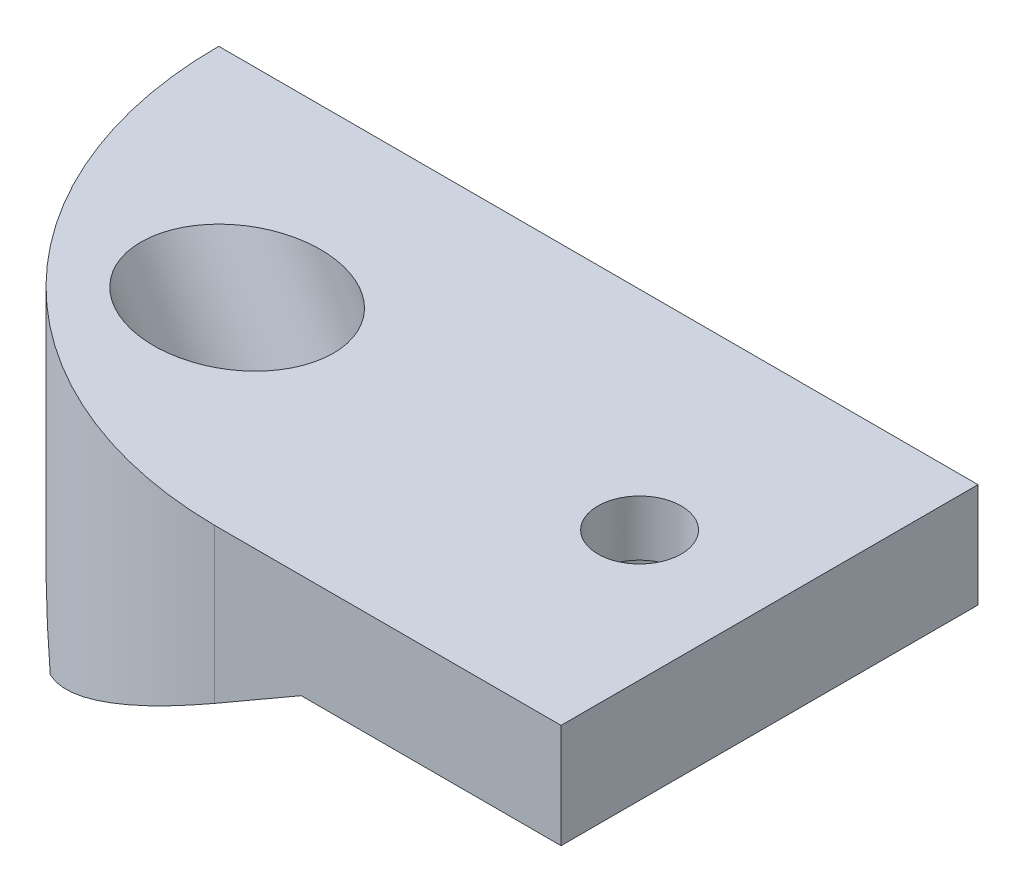
from build123d import *

# Parameters (mm, degrees)
ESBO_O1_W                = 30
ESBO_O1_H                = 30
RESSALTO_EXTRUS_O1_DEPTH = 22.775
CORTE_EXTRUS_O1_DEPTH    = 31
ESBO_O3_OUTSIDE_W        = 48.998
ESBO_O3_OUTSIDE_H        = 41.63
ESBO_O3_OUTSIDE_W_2      = 30
ESBO_O3_OUTSIDE_H_2      = 30
CORTE_EXTRUS_O2_DEPTH    = 20.723728571
RESSALTO_EXTRUS_O2_DEPTH = 30
ESBO_O5_R                = 3.95
CORTE_EXTRUS_O3_DEPTH    = 25.958558799
CORTE_EXTRUS_O5_START    = -8
ESBO_O8_R                = 6
CORTE_EXTRUS_O5_DEPTH    = 25
RESSALTO_EXTRUS_O6_DEPTH = 30
CORTE_EXTRUS_O11_DEPTH   = 26
ESBO_O19_R               = 6.35
CORTE_EXTRUS_O12_DEPTH   = 3.5
ESBO_O20_R               = 3
CORTE_EXTRUS_O13_DEPTH   = 26


with BuildPart() as part:
    # Esboço1 → Ressalto-extrusão1 (new body)
    with BuildSketch(Plane(origin=(0, 0, 0), x_dir=(1, 0, 0), z_dir=(0, 1, 0))):
        Rectangle(ESBO_O1_W, ESBO_O1_H)
    extrude(amount=RESSALTO_EXTRUS_O1_DEPTH)

    # Esboço2 → Corte-extrusão1 (cut, through all)
    with BuildSketch(Plane.XY.offset(15)):
        Polygon((-15, 0), (15, 17.320508076), (15, 0), align=None)
    extrude(amount=-CORTE_EXTRUS_O1_DEPTH, mode=Mode.SUBTRACT)

    # Esboço3 outside → Corte-extrusão2 (cut, through all)
    with BuildSketch(Plane(origin=(-3.75, 6.495190528, 0), x_dir=(0.866025404, 0.5, 0), z_dir=(0.5, -0.866025404, 0))):
        with Locations((5.694, 0)):
            Rectangle(ESBO_O3_OUTSIDE_W, ESBO_O3_OUTSIDE_H)
        with Locations((4.330127019, 0)):
            Rectangle(ESBO_O3_OUTSIDE_W_2, ESBO_O3_OUTSIDE_H_2, mode=Mode.SUBTRACT)
    extrude(amount=-CORTE_EXTRUS_O2_DEPTH, mode=Mode.SUBTRACT)

    # Esboço4 → Ressalto-extrusão2 (add)
    with BuildSketch(Plane.XY.offset(15)):
        Polygon((-25.469660456, 22.775), (-15, 4.641016151), (-15, 22.775), align=None)
    extrude(amount=-RESSALTO_EXTRUS_O2_DEPTH)

    # Esboço5 → Corte-extrusão3 (cut, through all)
    with BuildSketch(Plane(origin=(-3.75, 6.495190528, 0), x_dir=(-0.866025404, -0.5, 0), z_dir=(0.5, -0.866025404, 0))):
        with Locations((-4.330131096, -4.077e-06)):
            Circle(ESBO_O5_R)
    extrude(amount=-CORTE_EXTRUS_O3_DEPTH, mode=Mode.SUBTRACT)

    # Esboço8 → Corte-extrusão5 (cut)
    with BuildSketch(Plane(origin=(-3.75, 6.495190528, 0), x_dir=(0.866025404, 0.5, 0), z_dir=(0.5, -0.866025404, 0)).offset(CORTE_EXTRUS_O5_START)):
        with Locations((4.330131096, 4.077e-06)):
            Circle(ESBO_O8_R)
    extrude(amount=-CORTE_EXTRUS_O5_DEPTH, mode=Mode.SUBTRACT)

    # Esboço16 → Ressalto-extrusão6 (add)
    with BuildSketch(Plane.XY.offset(15)):
        Polygon((9.171355695, 22.775), (30.157076086, 22.775), (30.157076086, 15.275), (11.457076086, 15.275), align=None)
    extrude(amount=-RESSALTO_EXTRUS_O6_DEPTH)

    # Esboço17 → Corte-extrusão11 (cut)
    with BuildSketch(Plane(origin=(0, 22.775, 0), x_dir=(1, 0, 0), z_dir=(0, 1, 0))):
        with BuildLine():
            Line((5.221968449, -14.998459918), (5.221968449, -42.526473986))
            Line((5.221968449, -42.526473986), (-49.914065742, -42.526473986))
            Line((-49.914065742, -42.526473986), (-49.914065742, 15))
            Line((-49.914065742, 15), (-24.474999573, 15))
            ThreePointArc((-24.474999573, 15), (-15.795068431, -6.105787356), (5.221968449, -14.998459918))
        make_face()
    extrude(amount=-CORTE_EXTRUS_O11_DEPTH, mode=Mode.SUBTRACT)

    # Esboço19 → Corte-extrusão12 (cut)
    with BuildSketch(Plane.XZ.offset(-15.275)):
        with Locations((20.807076086, 0)):
            Circle(ESBO_O19_R)
    extrude(amount=-CORTE_EXTRUS_O12_DEPTH, mode=Mode.SUBTRACT)

    # Esboço20 → Corte-extrusão13 (cut)
    with BuildSketch(Plane.XZ.offset(-18.775)):
        with Locations((20.807076086, 0)):
            Circle(ESBO_O20_R)
    extrude(amount=-CORTE_EXTRUS_O13_DEPTH, mode=Mode.SUBTRACT)


solid = part.part
